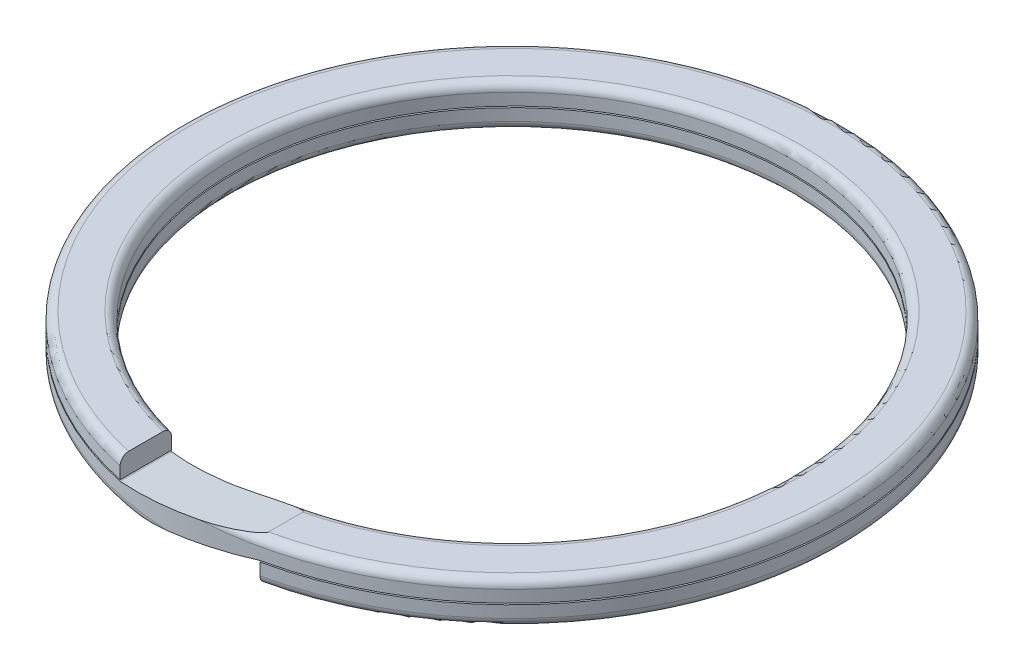
from build123d import *

# Parameters (mm, degrees)
CUT_EXTRUDE1_DEPTH      = 8.48
CUT_EXTRUDE2_DEPTH      = 8.48
CUT_EXTRUDE3_DEPTH      = 0.01
CUT_EXTRUDE3_DEPTH_BACK = 0.01


with BuildPart() as part:
    # Sketch3 → Revolve1 (revolve)
    with BuildSketch(Plane(origin=(0, 0, 0), x_dir=(0, 0, -1), z_dir=(1, 0, 0)), mode=Mode.PRIVATE) as revolve1_sk:
        with BuildLine():
            Line((4.368, -0.32), (4.872, -0.32))
            ThreePointArc((4.872, -0.32), (4.962509668, -0.282509668), (5, -0.192))
            Line((5, -0.192), (5, 0.192))
            ThreePointArc((5, 0.192), (4.962509668, 0.282509668), (4.872, 0.32))
            Line((4.872, 0.32), (4.368, 0.32))
            ThreePointArc((4.368, 0.32), (4.277490332, 0.282509668), (4.24, 0.192))
            Line((4.24, 0.192), (4.24, -0.192))
            ThreePointArc((4.24, -0.192), (4.277490332, -0.282509668), (4.368, -0.32))
        make_face()
    revolve(revolve1_sk.sketch.rotate(Axis((0, -1, 0), (0, 1, 0)), 180), axis=Axis((0, -1, 0), (0, 1, 0)))

    # Sketch1 → Cut-Extrude1 (cut)
    with BuildSketch(Plane.XY):
        Polygon((-1.06, 0.32), (-1.06, -0.01), (1.06, 0.32), align=None)
    extrude(amount=CUT_EXTRUDE1_DEPTH, mode=Mode.SUBTRACT)

    # Sketch2 → Cut-Extrude2 (cut)
    with BuildSketch(Plane.XY):
        Polygon((-1.06, -0.32), (1.06, -0.32), (1.06, 0.01), align=None)
    extrude(amount=CUT_EXTRUDE2_DEPTH, mode=Mode.SUBTRACT)

    # Sketch4 → Cut-Extrude3 (cut, two sides)
    with BuildSketch(Plane(origin=(0, 0, 0), x_dir=(1, 0, 0), z_dir=(0, 1, 0))) as cut_extrude3_sk:
        with BuildLine():
            Line((-5.544, -5.544), (-1.06, -5.544))
            Line((-1.06, -5.544), (-1.06, -4.0019995))
            ThreePointArc((-1.06, -4.0019995), (0, -4.14), (1.06, -4.0019995))
            Line((1.06, -4.0019995), (1.06, -5.544))
            Line((1.06, -5.544), (5.544, -5.544))
            Line((5.544, -5.544), (5.544, 5.544))
            Line((5.544, 5.544), (-5.544, 5.544))
            Line((-5.544, 5.544), (-5.544, -5.544))
        make_face()
    extrude(amount=CUT_EXTRUDE3_DEPTH, mode=Mode.SUBTRACT)
    extrude(cut_extrude3_sk.sketch, amount=-CUT_EXTRUDE3_DEPTH_BACK, mode=Mode.SUBTRACT)


solid = part.part
